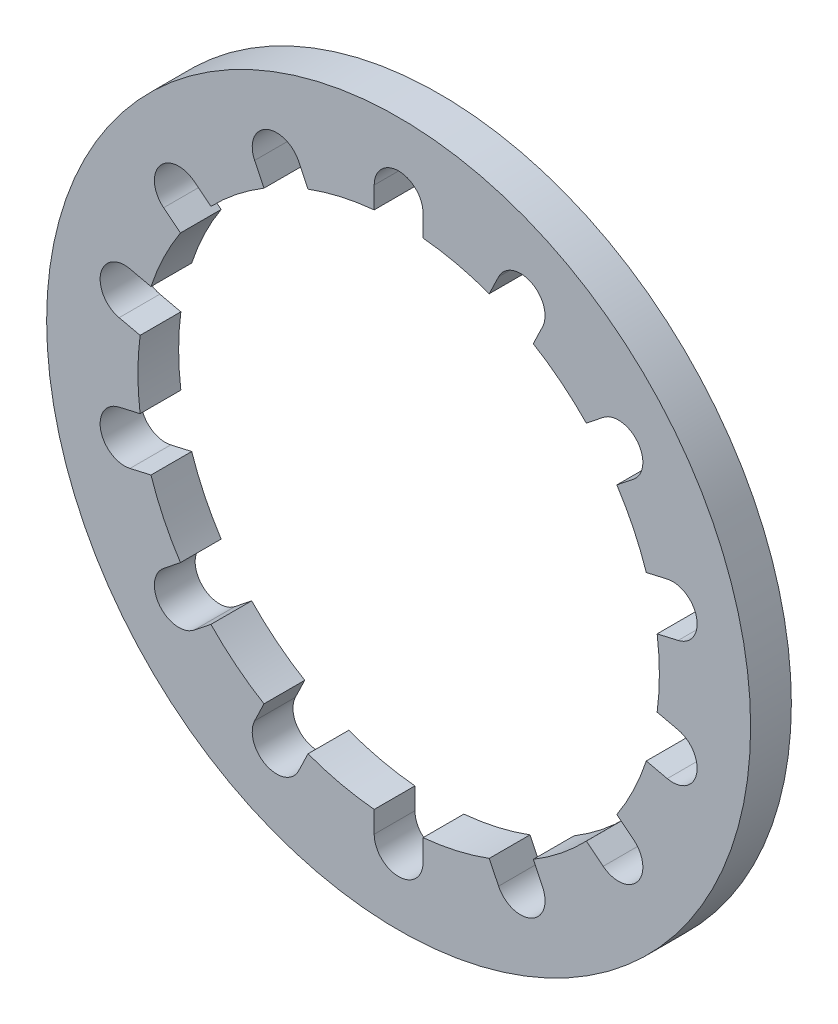
from build123d import *

# Parameters (mm, degrees)
SKETCH1_R          = 5.4864
BASE_EXTRUDE_DEPTH = 0.635
SKETCH2_R          = 4.064
CUT_EXTRUDE1_DEPTH = 1.635
CUT_EXTRUDE4_DEPTH = 1.635
CIRPATTERN1_COUNT  = 14


with BuildPart() as part:
    # Sketch1 → Base-Extrude (new body)
    with BuildSketch(Plane.XY):
        Circle(SKETCH1_R)
    extrude(amount=BASE_EXTRUDE_DEPTH)

    # Sketch2 → Cut-Extrude1 (cut, through all)
    with BuildSketch(Plane.XY.offset(0.635)):
        Circle(SKETCH2_R)
    extrude(amount=-CUT_EXTRUDE1_DEPTH, mode=Mode.SUBTRACT)

    # Sketch3 → Cut-Extrude4 (cut, through all)
    with BuildSketch(Plane.XY.offset(0.635)):
        with BuildLine():
            Line((0.381, 4.04610121), (0.381, 4.3815))
            ThreePointArc((0.381, 4.3815), (0, 4.7625), (-0.381, 4.3815))
            Line((-0.381, 4.3815), (-0.381, 4.04610121))
            ThreePointArc((-0.381, 4.04610121), (0, 4.064), (0.381, 4.04610121))
        make_face()
    cut_extrude4 = extrude(amount=-CUT_EXTRUDE4_DEPTH, mode=Mode.SUBTRACT)

    # CirPattern1: Cut-Extrude4 ×14 about axis
    cirpattern1_axis = Axis((0, 0, 0), (0, 0, 1))
    for i in range(1, CIRPATTERN1_COUNT):
        add(cut_extrude4.rotate(cirpattern1_axis, i * 360 / CIRPATTERN1_COUNT), mode=Mode.SUBTRACT)


solid = part.part
